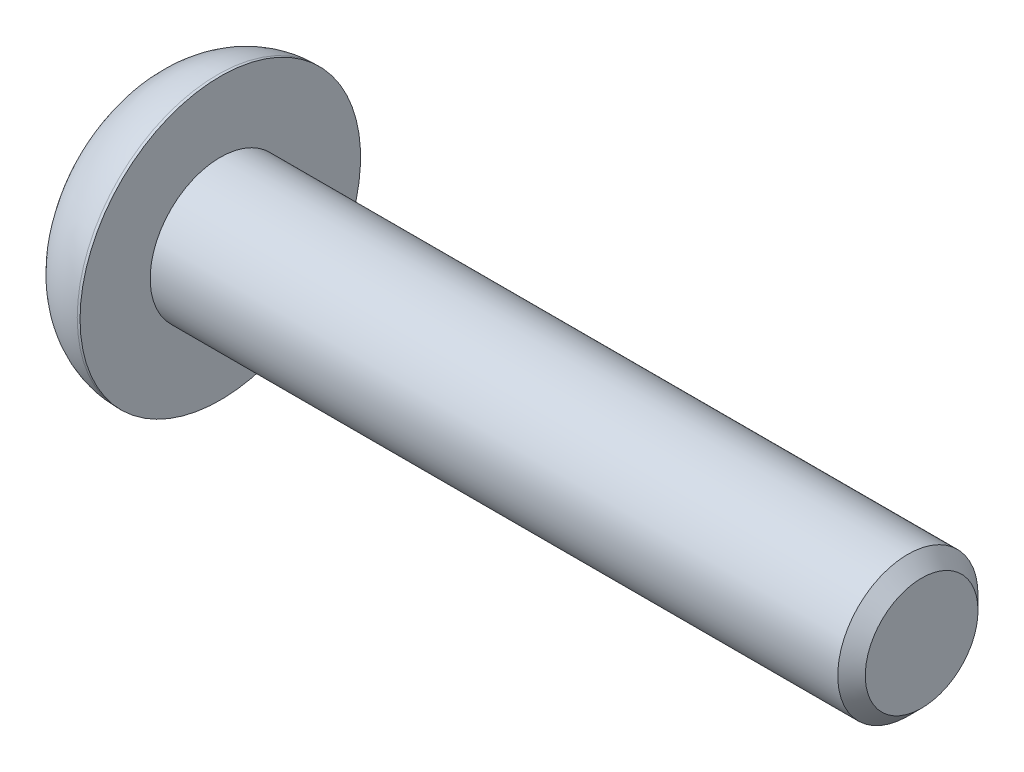
from build123d import *

# Parameters (mm, degrees)
SKETCH_1_W                = 2.8
SKETCH_1_H                = 5
SKETCH_2_R                = 2.5
EXTRUDE_1_DEPTH           = 25
CUT_EXTRUDE_1_DEPTH       = 1.82
HOLE_WIZARD_3_0_3_1_D     = 3
HOLE_WIZARD_3_0_3_1_DEPTH = 0.113974596
HOLE_WIZARD_3_0_3_1_TIP   = 0.866025404
CHAMFER_1_SIZE            = 0.4905
FILLET_1_R                = 2.7


with BuildPart() as part:
    # Эскиз1 → Повернуть1 (revolve)
    with BuildSketch(Plane(origin=(0, 0, 0), x_dir=(-1, 0, 0), z_dir=(0, 0, -1))):
        with Locations((-1.4, 2.5)):
            Rectangle(SKETCH_1_W, SKETCH_1_H)
    revolve(axis=Axis((2.8, 0, 0), (-1, 0, 0)))

    # Эскиз2 → Бобышка-Вытянуть1 (add)
    with BuildSketch(Plane(origin=(2.8, 0, 0), x_dir=(0, 0, -1), z_dir=(1, 0, 0))):
        Circle(SKETCH_2_R)
    extrude(amount=EXTRUDE_1_DEPTH)

    # Эскиз3 → Вырез-Вытянуть1 (cut)
    with BuildSketch(Plane.ZY):
        Polygon((0, 1.732050808), (-1.5, 0.866025404), (-1.5, -0.866025404), (0, -1.732050808), (1.5, -0.866025404), (1.5, 0.866025404), align=None)
    extrude(amount=-CUT_EXTRUDE_1_DEPTH, mode=Mode.SUBTRACT)

    # Диаметр отверстия Ø3.0 (3)1
    with Locations(Plane.ZY.offset(-1.82)):
        with Locations((0, 0)):
            Hole(HOLE_WIZARD_3_0_3_1_D / 2, depth=HOLE_WIZARD_3_0_3_1_DEPTH)
            with Locations((0, 0, -(HOLE_WIZARD_3_0_3_1_DEPTH + HOLE_WIZARD_3_0_3_1_TIP / 2))):  # 120° drill point
                Cone(0, HOLE_WIZARD_3_0_3_1_D / 2, HOLE_WIZARD_3_0_3_1_TIP, mode=Mode.SUBTRACT)

    # Фаска1
    chamfer_1_edges = [part.edges().sort_by_distance(p)[0] for p in [
        (27.8, 0, 2.5),
    ]]
    chamfer(chamfer_1_edges, length=CHAMFER_1_SIZE)

    # Скругление1
    fillet_1_edges = [part.edges().sort_by_distance(p)[0] for p in [
        (0, -5, 0),
    ]]
    fillet(fillet_1_edges, radius=FILLET_1_R)


solid = part.part
